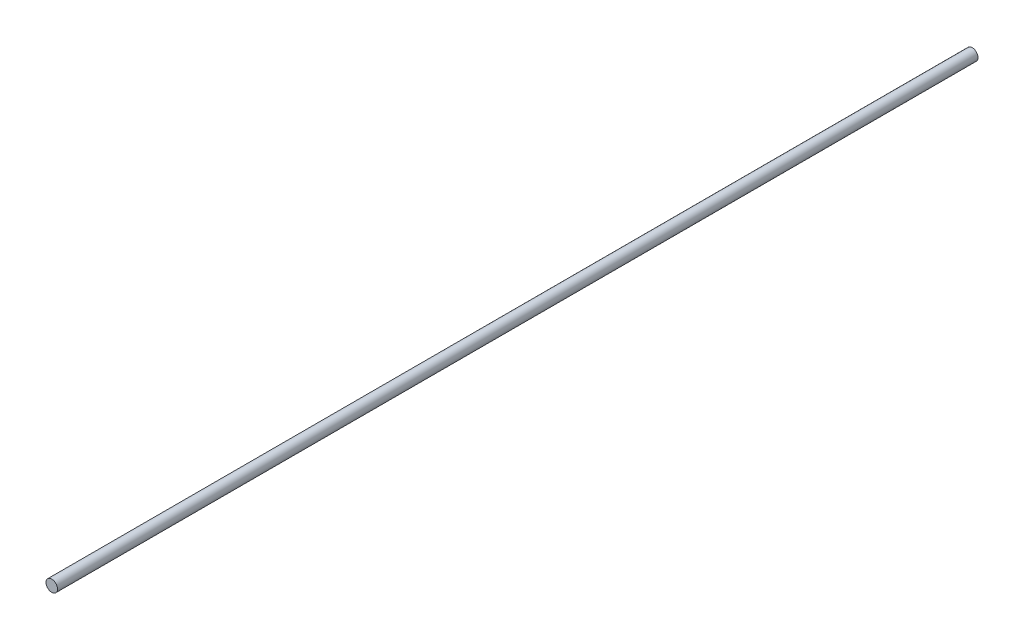
from build123d import *

# Parameters (mm, degrees)
ESQUISSE1_R        = 4
BOSS_EXTRU_1_DEPTH = 640


with BuildPart() as part:
    # Esquisse1 → Boss.-Extru.1 (new body)
    with BuildSketch(Plane.XY):
        Circle(ESQUISSE1_R)
    extrude(amount=BOSS_EXTRU_1_DEPTH)


solid = part.part
